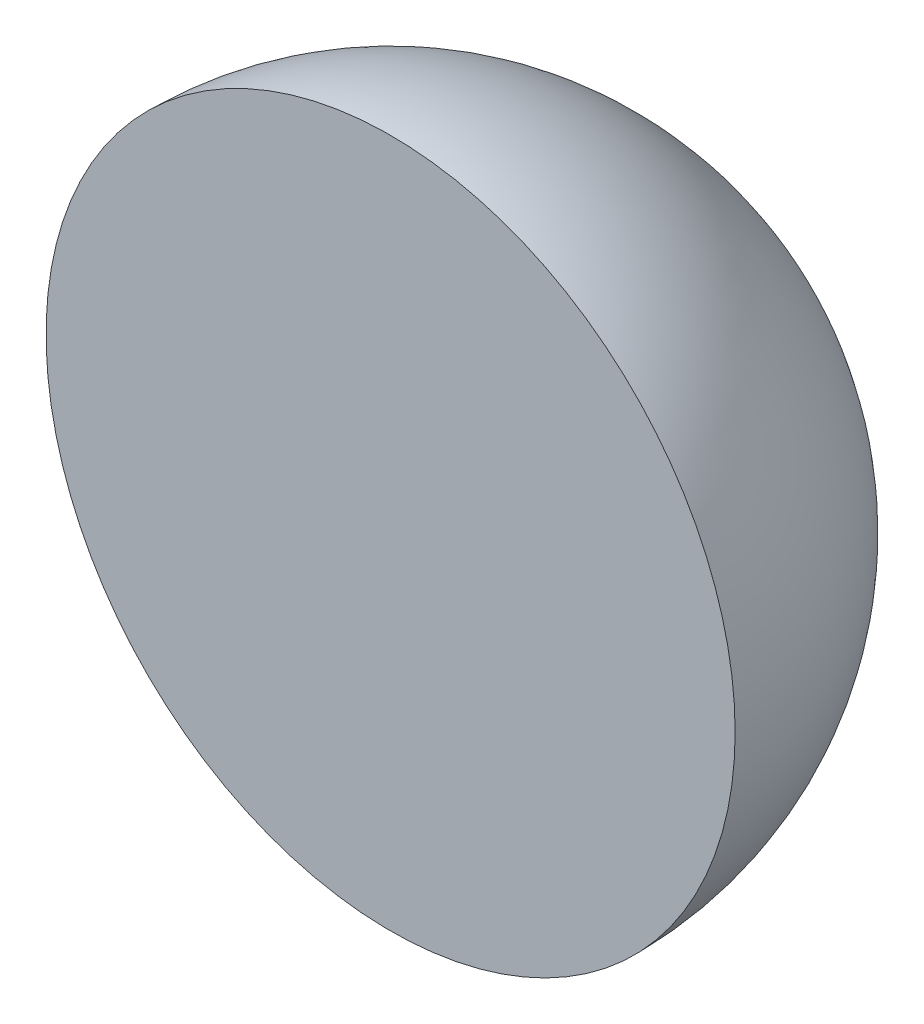
from build123d import *

# Parameters (mm, degrees)
OBR_T1_ANGLE = 180


with BuildPart() as part:
    # Szkic1 → Obrót1 (revolve)
    with BuildSketch(Plane.XY):
        with BuildLine():
            Line((0, 0), (0, 6190))
            ThreePointArc((0, 6190), (3095, 3095), (0, 0))
        make_face()
    revolve(axis=Axis((0, 0, 0), (0, 1, 0)), revolution_arc=OBR_T1_ANGLE)


solid = part.part
